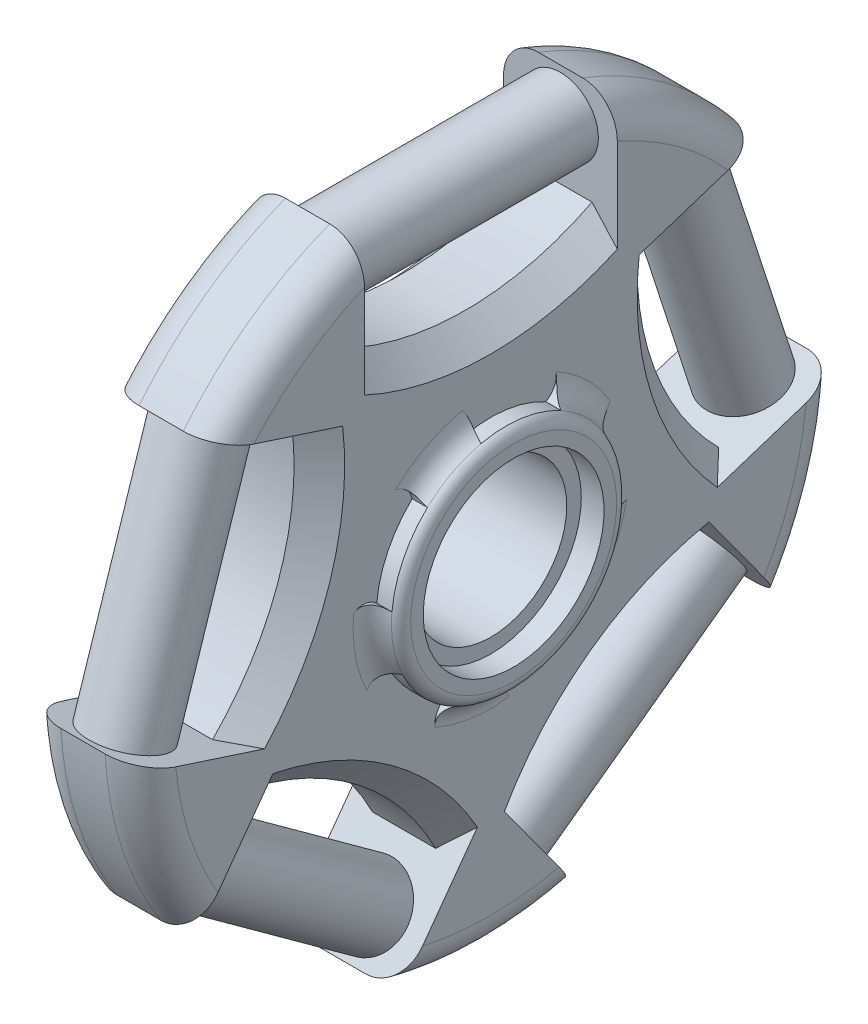
from build123d import *

# Parameters (mm, degrees)
SKETCH1_R                = 6
BOSS_EXTRUDE2_DEPTH      = 9
FILLET1_R                = 2.75
SKETCH3_R                = 9.15
SKETCH3_R_2              = 7.15
BOSS_EXTRUDE3_DEPTH      = 1.8
BOSS_EXTRUDE3_DEPTH_BACK = 10.8
CHAMFER2_SIZE            = 2
FILLET3_R                = 1
FILLET4_R                = 2
CUT_EXTRUDE1_DEPTH       = 1.8
SKETCH6_R                = 3
BOSS_EXTRUDE4_DEPTH      = 20
SKETCH7_R                = 3
BOSS_EXTRUDE5_DEPTH      = 20
SKETCH8_R                = 3
BOSS_EXTRUDE6_DEPTH      = 20
SKETCH9_R                = 3
BOSS_EXTRUDE7_DEPTH      = 20
SKETCH10_R               = 3
BOSS_EXTRUDE8_DEPTH      = 20


with BuildPart() as part:
    # Sketch1 → Boss-Extrude2 (new body)
    with BuildSketch(Plane(origin=(0, 0, 0), x_dir=(0, 0, -1), z_dir=(1, 0, 0))):
        with BuildLine():
            Line((13.838636046, 15.011067663), (21.579436807, 17.526206295))
            ThreePointArc((21.579436807, 17.526206295), (16.340430014, 22.490672444), (10, 25.939159585))
            Line((10, 25.939159585), (10, 17.8))
            ThreePointArc((10, 17.8), (0, 15.395917942), (-10, 17.8))
            Line((-10, 17.8), (-10, 25.939159585))
            ThreePointArc((-10, 25.939159585), (-16.340430014, 22.490672444), (-21.579436807, 17.526206295))
            Line((-21.579436807, 17.526206295), (-13.838636046, 15.011067663))
            ThreePointArc((-13.838636046, 15.011067663), (-14.642388083, 4.757600288), (-20.018975934, -4.010062663))
            Line((-20.018975934, -4.010062663), (-27.759776695, -1.494924031))
            ThreePointArc((-27.759776695, -1.494924031), (-26.439371153, -8.590672444), (-23.336825405, -15.107368402))
            Line((-23.336825405, -15.107368402), (-18.552747435, -8.522649977))
            ThreePointArc((-18.552747435, -8.522649977), (-9.049493512, -12.455559259), (-2.372407547, -20.278355023))
            Line((-2.372407547, -20.278355023), (-7.156485517, -26.863073447))
            ThreePointArc((-7.156485517, -26.863073447), (0, -27.8), (7.156485517, -26.863073447))
            Line((7.156485517, -26.863073447), (2.372407547, -20.278355023))
            ThreePointArc((2.372407547, -20.278355023), (9.049493512, -12.455559259), (18.552747435, -8.522649977))
            Line((18.552747435, -8.522649977), (23.336825405, -15.107368402))
            ThreePointArc((23.336825405, -15.107368402), (26.439371153, -8.590672444), (27.759776695, -1.494924031))
            Line((27.759776695, -1.494924031), (20.018975934, -4.010062663))
            ThreePointArc((20.018975934, -4.010062663), (14.642388083, 4.757600288), (13.838636046, 15.011067663))
        make_face()
        Circle(SKETCH1_R, mode=Mode.SUBTRACT)
    extrude(amount=BOSS_EXTRUDE2_DEPTH)

    # Fillet1
    fillet1_edges = [part.edges().sort_by_distance(p)[0] for p in [
        (9, -8.590672444, 26.439371153),
        (0, 22.490672444, 16.340430014),
        (0, 22.490672444, -16.340430014),
        (0, -8.590672444, -26.439371153),
        (0, -27.8, 0),
        (0, -8.590672444, 26.439371153),
        (9, -27.8, 0),
        (9, -8.590672444, -26.439371153),
        (9, 22.490672444, -16.340430014),
        (9, 22.490672444, 16.340430014),
    ]]
    fillet(fillet1_edges, radius=FILLET1_R)

    # Sketch3 → Boss-Extrude3 (add, two sides)
    with BuildSketch(Plane.ZY) as boss_extrude3_sk:
        Circle(SKETCH3_R)
        Circle(SKETCH3_R_2, mode=Mode.SUBTRACT)
    extrude(amount=BOSS_EXTRUDE3_DEPTH)
    extrude(boss_extrude3_sk.sketch, amount=-BOSS_EXTRUDE3_DEPTH_BACK)

    # Chamfer2
    chamfer2_edges = [part.edges().sort_by_distance(p)[0] for p in [
        (9, 4.757600288, 14.642388083),
        (0, 15.395917942, 0),
        (0, 4.757600288, -14.642388083),
        (0, -12.455559259, -9.049493512),
        (0, -12.455559259, 9.049493512),
        (0, 4.757600288, 14.642388083),
        (9, -12.455559259, 9.049493512),
        (9, -12.455559259, -9.049493512),
        (9, 4.757600288, -14.642388083),
        (9, 15.395917942, 0),
    ]]
    chamfer(chamfer2_edges, length=CHAMFER2_SIZE)

    # Fillet3
    fillet3_edges = [part.edges().sort_by_distance(p)[0] for p in [
        (10.8, 0, -9.15),
        (-1.8, 0, -9.15),
    ]]
    fillet(fillet3_edges, radius=FILLET3_R)

    # Fillet4
    fillet4_edges = [part.edges().sort_by_distance(p)[0] for p in [
        (0, 0, -9.15),
        (9, 0, -9.15),
    ]]
    fillet(fillet4_edges, radius=FILLET4_R)

    # Sketch5 → Cut-Extrude1 (cut)
    with BuildSketch(Plane.ZY):
        with BuildLine():
            ThreePointArc((9.80906264, -4.752092216), (7.571460458, -7.840476824), (4.40686602, -9.96893285))
            ThreePointArc((4.40686602, -9.96893285), (4.258003432, -9.018393882), (3.590916291, -8.325083601))
            ThreePointArc((3.590916291, -8.325083601), (6.298130632, -6.52190519), (8.194691013, -3.87927003))
            ThreePointArc((8.194691013, -3.87927003), (9.13945571, -4.061215266), (9.80906264, -4.752092216))
        make_face()
        with BuildLine():
            ThreePointArc((-1.157106253, -8.992374652), (-1.038198109, -9.947123443), (-1.488341213, -10.797450196))
            ThreePointArc((-1.488341213, -10.797450196), (-5.117026621, -9.623727389), (-8.119222056, -7.271748312))
            ThreePointArc((-8.119222056, -7.271748312), (-7.261206845, -6.836438882), (-6.807970848, -5.98775665))
            ThreePointArc((-6.807970848, -5.98775665), (-4.256471031, -8.005257718), (-1.157106253, -8.992374652))
        make_face()
        with BuildLine():
            ThreePointArc((-8.909822006, -1.678323145), (-9.781097428, -2.086445112), (-10.728908096, -1.921098997))
            ThreePointArc((-10.728908096, -1.921098997), (-10.733956831, 1.892686199), (-9.424821213, 5.474745236))
            ThreePointArc((-9.424821213, 5.474745236), (-8.745676062, 4.793242291), (-7.798473669, 4.624446474))
            ThreePointArc((-7.798473669, 4.624446474), (-8.928774402, 1.574383832), (-8.909822006, -1.678323145))
        make_face()
        with BuildLine():
            ThreePointArc((-4.34946658, 7.955113904), (-5.006852549, 8.657629448), (-5.142488653, 9.61014572))
            ThreePointArc((-5.142488653, 9.61014572), (-1.516923535, 10.79347179), (2.294362208, 10.655326947))
            ThreePointArc((2.294362208, 10.655326947), (1.856081784, 9.798825534), (1.98824906, 8.845821751))
            ThreePointArc((1.98824906, 8.845821751), (-1.261815027, 8.978280437), (-4.34946658, 7.955113904))
        make_face()
        with BuildLine():
            ThreePointArc((6.221703827, 6.594853922), (6.686692376, 7.437154373), (7.550675322, 7.860495689))
            ThreePointArc((7.550675322, 7.860495689), (9.796446528, 4.778046224), (10.84281504, 1.110608978))
            ThreePointArc((10.84281504, 1.110608978), (9.892797691, 1.262764939), (9.027279166, 0.842572026))
            ThreePointArc((9.027279166, 0.842572026), (8.148929828, 3.974498639), (6.221703827, 6.594853922))
        make_face()
    cut_extrude1 = extrude(amount=CUT_EXTRUDE1_DEPTH, mode=Mode.SUBTRACT)

    # Mirror1: Cut-Extrude1 across plane
    add(cut_extrude1.mirror(Plane(origin=(4.5, 0, 0), x_dir=(0, 0, 1), z_dir=(1, 0, 0))), mode=Mode.SUBTRACT)

    # Sketch6 → Boss-Extrude4 (add)
    with BuildSketch(Plane(origin=(0, -5.877852523, -8.090169944), x_dir=(1, 0, 0), z_dir=(0, 0.587785252, 0.809016994))):
        with Locations((4.5, -22.439159585)):
            Circle(SKETCH6_R)
    extrude(amount=BOSS_EXTRUDE4_DEPTH)

    # Sketch7 → Boss-Extrude5 (add)
    with BuildSketch(Plane(origin=(0, -9.510565163, 3.090169944), x_dir=(1, 0, 0), z_dir=(0, 0.951056516, -0.309016994))):
        with Locations((4.5, -22.439159585)):
            Circle(SKETCH7_R)
    extrude(amount=BOSS_EXTRUDE5_DEPTH)

    # Sketch8 → Boss-Extrude6 (add)
    with BuildSketch(Plane.XY.offset(-10)):
        with Locations((4.5, 22.439159585)):
            Circle(SKETCH8_R)
    extrude(amount=BOSS_EXTRUDE6_DEPTH)

    # Sketch9 → Boss-Extrude7 (add)
    with BuildSketch(Plane(origin=(0, -5.877852523, 8.090169944), x_dir=(-1, 0, 0), z_dir=(0, 0.587785252, -0.809016994))):
        with Locations((-4.5, -22.439159585)):
            Circle(SKETCH9_R)
    extrude(amount=BOSS_EXTRUDE7_DEPTH)

    # Sketch10 → Boss-Extrude8 (add)
    with BuildSketch(Plane(origin=(0, -9.510565163, -3.090169944), x_dir=(1, 0, 0), z_dir=(0, 0.951056516, 0.309016994))):
        with Locations((4.5, 22.439159585)):
            Circle(SKETCH10_R)
    extrude(amount=BOSS_EXTRUDE8_DEPTH)


solid = part.part
